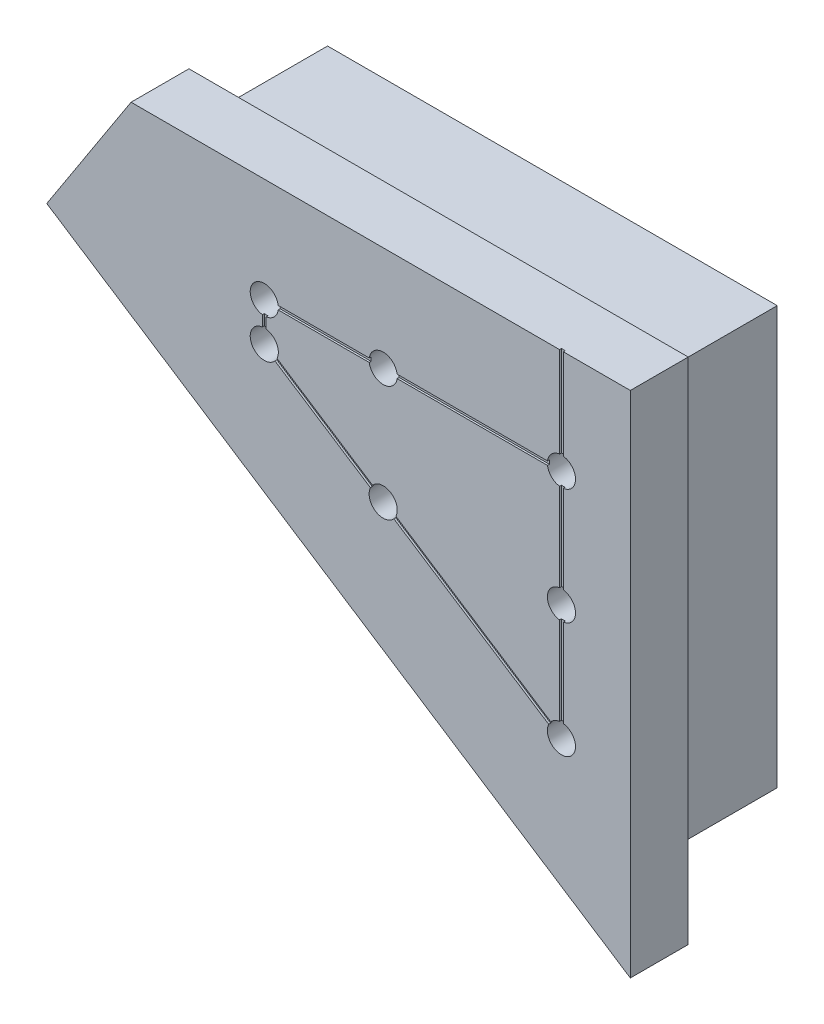
from build123d import *

# Parameters (mm, degrees)
BOSS_EXTRUDE1_DEPTH                             = 70.7898
CBORE_FOR_10_SOCKET_HEAD_CAP_SCREW1_D           = 5.5372
CBORE_FOR_10_SOCKET_HEAD_CAP_SCREW1_CBORE_D     = 11.1252
CBORE_FOR_10_SOCKET_HEAD_CAP_SCREW1_CBORE_DEPTH = 66.8274
BOSS_EXTRUDE2_DEPTH                             = 22.8854
FILLET2_R                                       = 2.3368
CUT_EXTRUDE1_DEPTH                              = 0.762


with BuildPart() as part:
    # Sketch1 → Boss-Extrude1 (new body)
    with BuildSketch(Plane.XY):
        Polygon((-177.8, 0), (-200.472065098, -34.911918701), (0, -165.1), (0, 0), align=None)
    extrude(amount=BOSS_EXTRUDE1_DEPTH)

    # CBORE for #10 Socket Head Cap Screw1 (through all)
    with Locations(Plane.XY.offset(70.7898)):
        with Locations((-132.031708342, -28.575), (-14.535778015, -28.575), (-14.535778015, -74.350066155), (-14.535778015, -120.125132311), (-85.023198604, -74.350066155), (-85.023198604, -28.575), (-132.031708342, -43.822382986)):
            CounterBoreHole(CBORE_FOR_10_SOCKET_HEAD_CAP_SCREW1_D / 2, CBORE_FOR_10_SOCKET_HEAD_CAP_SCREW1_CBORE_D / 2, CBORE_FOR_10_SOCKET_HEAD_CAP_SCREW1_CBORE_DEPTH)

    # Sketch13 → Boss-Extrude2 (add)
    with BuildSketch(Plane.XY.offset(70.7898)):
        Polygon((12.7, 12.7), (-184.695537385, 12.7), (-218.040097055, -38.64611917), (12.7, -188.490490253), align=None)
        Polygon((0, -165.1), (0, 0), (-177.8, 0), (-200.472065098, -34.911918701), align=None, mode=Mode.SUBTRACT)
    extrude(amount=-BOSS_EXTRUDE2_DEPTH)

    # Fillet2
    fillet2_edges = [part.edges().sort_by_distance(p)[0] for p in [
        (-189.136032549, -17.455959351, 47.9044),
        (-100.236032549, -100.005959351, 47.9044),
        (0, -82.55, 47.9044),
        (-88.9, 0, 47.9044),
    ]]
    fillet(fillet2_edges, radius=FILLET2_R)

    # Sketch14 → Cut-Extrude1 (cut)
    with BuildSketch(Plane.XY.offset(70.7898)):
        with BuildLine():
            Line((-14.950792959, -120.764199283), (-132.446723286, -44.461449959))
            ThreePointArc((-132.446723286, -44.461449959), (-132.701366981, -44.185977962), (-132.793708342, -43.822382986))
            Line((-132.793708342, -43.822382986), (-132.793708342, -28.575))
            ThreePointArc((-132.793708342, -28.575), (-132.570523709, -28.036184633), (-132.031708342, -27.813))
            Line((-132.031708342, -27.813), (-15.297778015, -27.813))
            Line((-15.297778015, -27.813), (-15.297778015, 12.7))
            Line((-15.297778015, 12.7), (-13.773778015, 12.7))
            Line((-13.773778015, 12.7), (-13.773778015, -120.125132311))
            ThreePointArc((-13.773778015, -120.125132311), (-14.172183039, -120.79479095), (-14.950792959, -120.764199283))
        make_face()
        with BuildLine():
            Line((-16.474792959, -117.957340453), (-130.922723286, -43.633985473))
            ThreePointArc((-130.922723286, -43.633985473), (-131.177366981, -43.358513475), (-131.269708342, -42.9949185))
            Line((-131.269708342, -42.9949185), (-131.269708342, -30.099))
            ThreePointArc((-131.269708342, -30.099), (-131.046523709, -29.560184633), (-130.507708342, -29.337))
            Line((-130.507708342, -29.337), (-15.297778015, -29.337))
            Line((-15.297778015, -29.337), (-15.297778015, -117.31827348))
            ThreePointArc((-15.297778015, -117.31827348), (-15.696183039, -117.98793212), (-16.474792959, -117.957340453))
        make_face(mode=Mode.SUBTRACT)
    extrude(amount=-CUT_EXTRUDE1_DEPTH, mode=Mode.SUBTRACT)


solid = part.part
